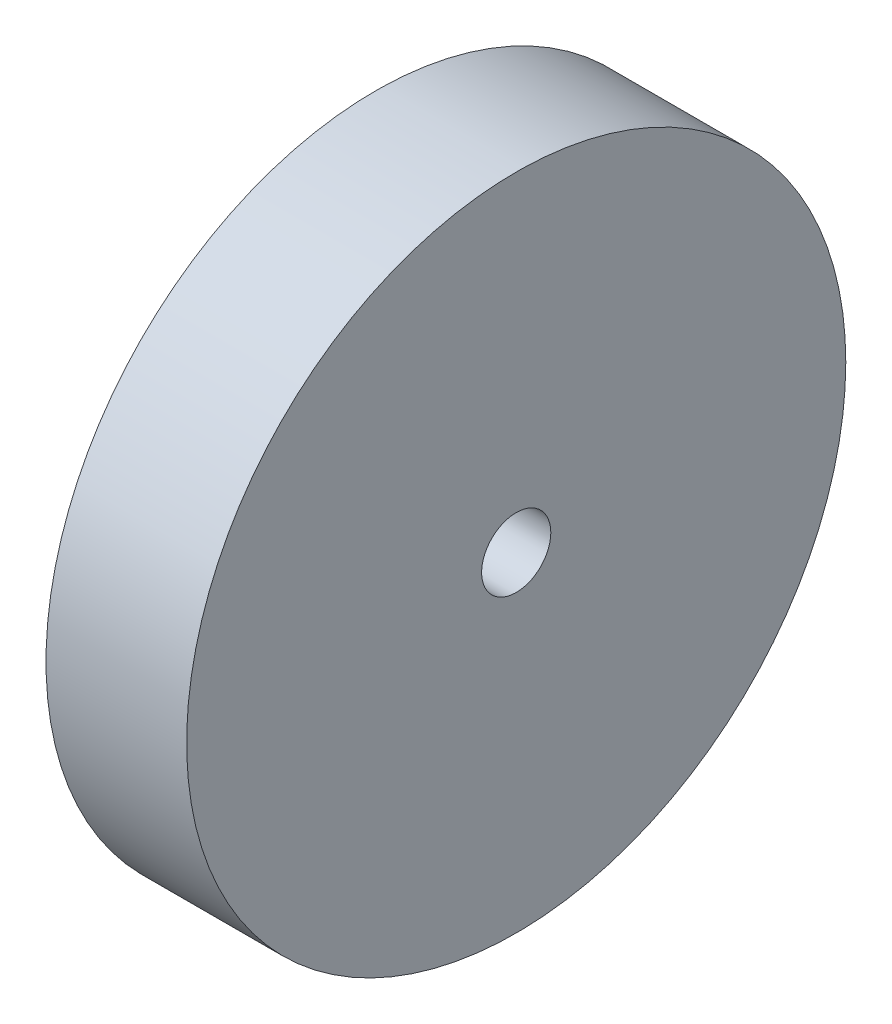
from build123d import *

# Parameters (mm, degrees)
SKETCH1_R           = 23.8125
SKETCH1_R_2         = 2.5
BOSS_EXTRUDE1_DEPTH = 5.08


with BuildPart() as part:
    # Sketch1 → Boss-Extrude1 (new body, symmetric)
    with BuildSketch(Plane(origin=(0, 0, 0), x_dir=(0, 0, -1), z_dir=(1, 0, 0))):
        Circle(SKETCH1_R)
        Circle(SKETCH1_R_2, mode=Mode.SUBTRACT)
    extrude(amount=BOSS_EXTRUDE1_DEPTH, both=True)


solid = part.part
